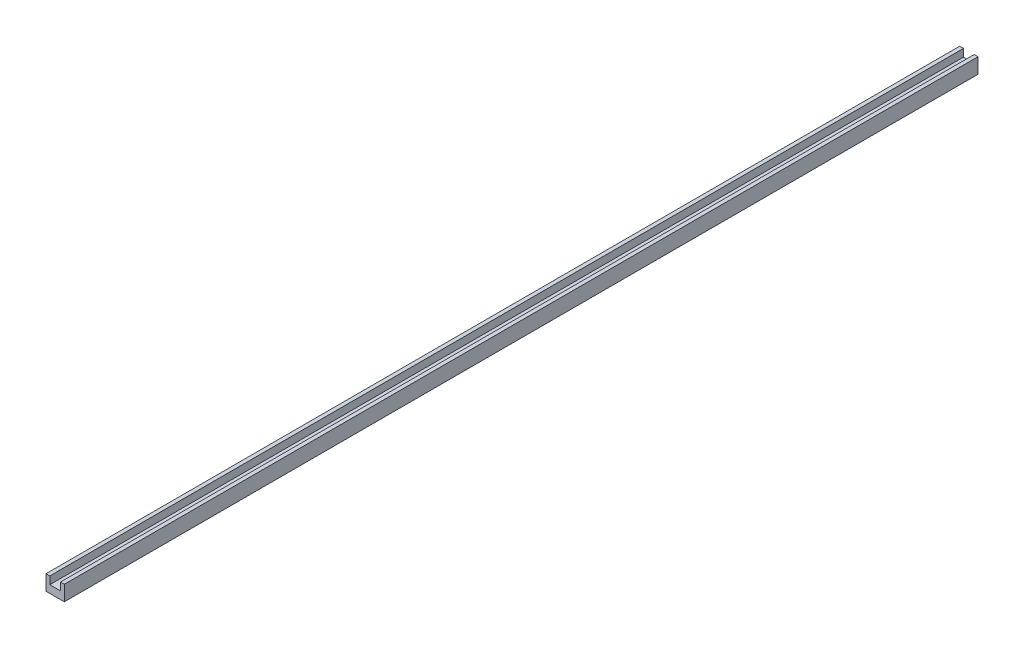
from build123d import *

# Parameters (mm, degrees)
SKETCH2_W           = 12
SKETCH2_H           = 10
BOSS_EXTRUDE1_DEPTH = 600
SKETCH4_W           = 7
SKETCH4_H           = 5
CUT_EXTRUDE1_DEPTH  = 601


with BuildPart() as part:
    # Sketch2 → Boss-Extrude1 (new body)
    with BuildSketch(Plane.XY):
        with Locations((6, 5)):
            Rectangle(SKETCH2_W, SKETCH2_H)
    extrude(amount=BOSS_EXTRUDE1_DEPTH)

    # Sketch4 → Cut-Extrude1 (cut, through all)
    with BuildSketch(Plane.XY.offset(600)):
        with Locations((6, 7.5)):
            Rectangle(SKETCH4_W, SKETCH4_H)
    extrude(amount=-CUT_EXTRUDE1_DEPTH, mode=Mode.SUBTRACT)


solid = part.part
